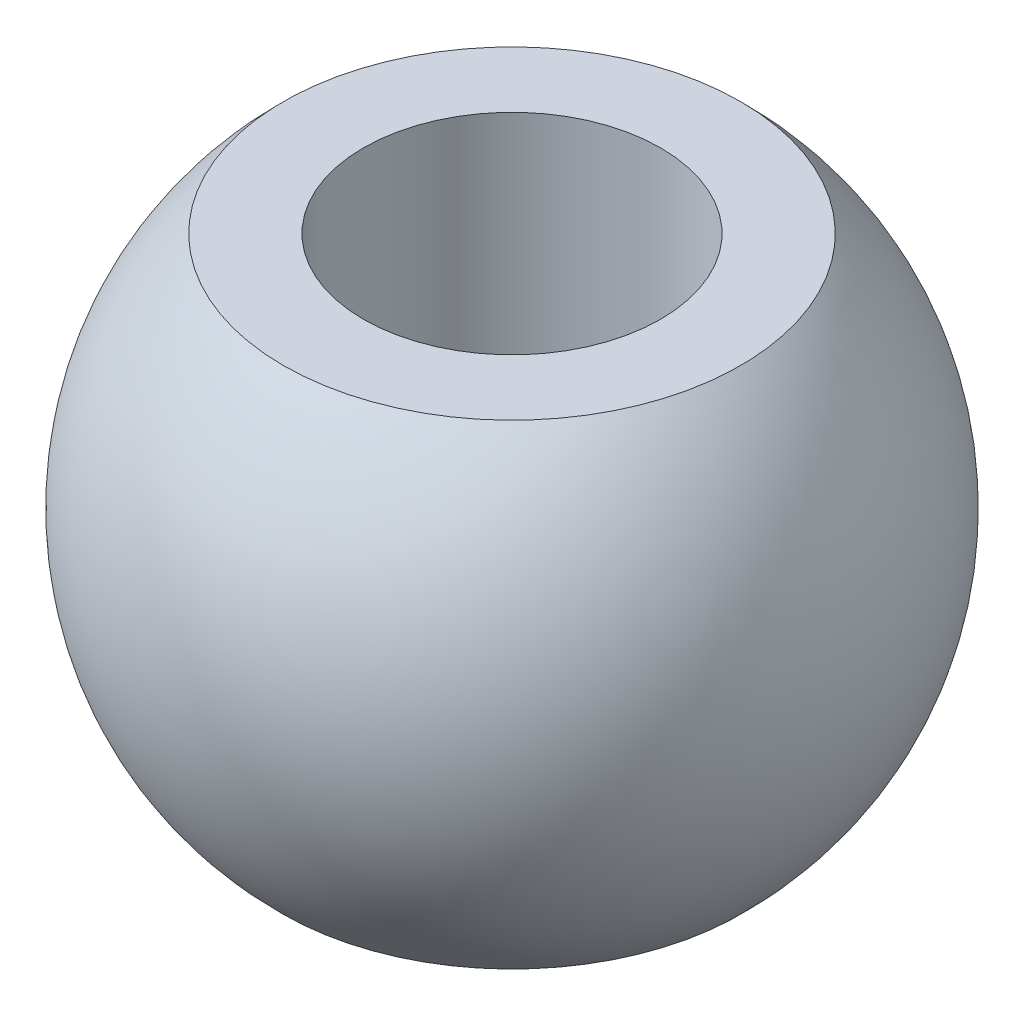
from build123d import *


with BuildPart() as part:
    # Szkic1 → Obrót1 (revolve)
    with BuildSketch(Plane.XY):
        with BuildLine():
            Line((2.5, -4), (2.5, 4))
            Line((2.5, 4), (3.847401721, 4))
            ThreePointArc((3.847401721, 4), (5.55, 0), (3.847401721, -4))
            Line((3.847401721, -4), (2.5, -4))
        make_face()
    revolve(axis=Axis((0, -11.1, 0), (0, 1, 0)))


solid = part.part
